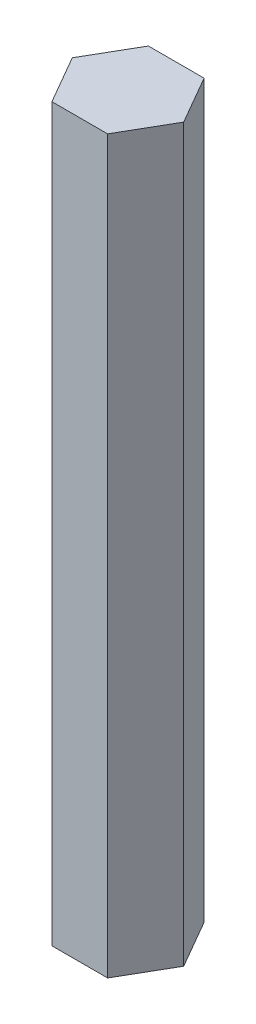
from build123d import *

# Parameters (mm, degrees)
BOSS_EXTRUDE1_DEPTH = 105


with BuildPart() as part:
    # Sketch1 → Boss-Extrude1 (new body)
    with BuildSketch(Plane(origin=(0, 0, 0), x_dir=(1, 0, 0), z_dir=(0, 1, 0))):
        Polygon((7.977059052, 1.579344013), (3.977059052, 8.507547244), (-4.022940948, 8.507547244), (-8.022940948, 1.579344013), (-4.022940948, -5.348859217), (3.977059052, -5.348859217), align=None)
    extrude(amount=BOSS_EXTRUDE1_DEPTH)


solid = part.part
